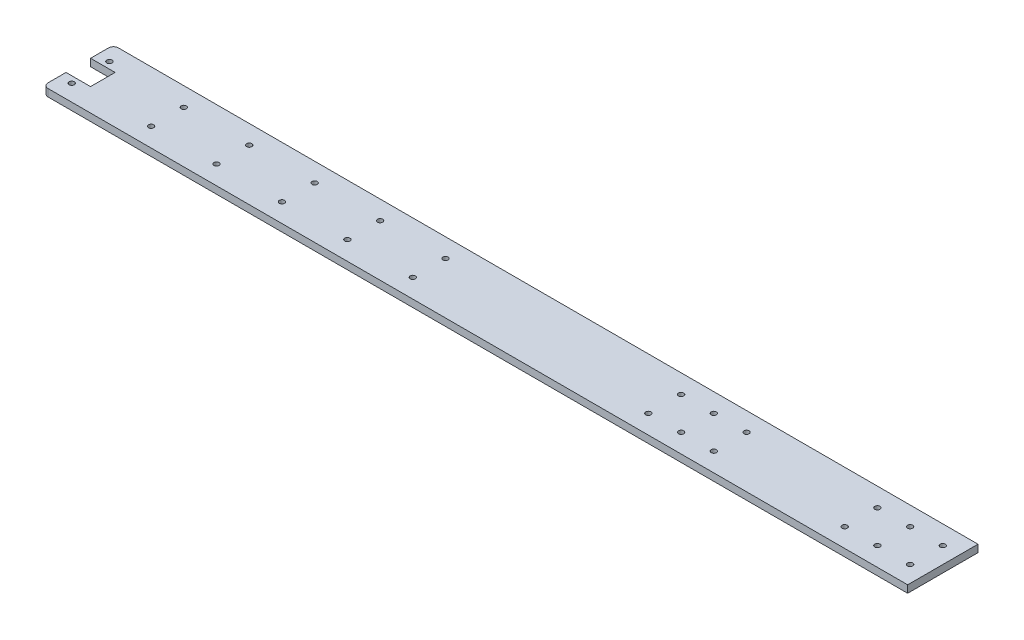
from build123d import *

# Parameters (mm, degrees)
SKETCH1_W           = 528.5
SKETCH1_H           = 43
SKETCH1_R           = 1.6
BOSS_EXTRUDE1_DEPTH = 4.5
SKETCH2_R           = 1.6
SKETCH2_W           = 15
SKETCH2_H           = 15
CUT_EXTRUDE1_DEPTH  = 5.5
FILLET1_R           = 3


with BuildPart() as part:
    # Sketch1 → Boss-Extrude1 (new body)
    with BuildSketch(Plane(origin=(0, 0, 0), x_dir=(1, 0, 0), z_dir=(0, 1, 0))):
        Rectangle(SKETCH1_W, SKETCH1_H)
        with Locations((-209.75, 10)):
            Circle(SKETCH1_R, mode=Mode.SUBTRACT)
        with Locations((-169.75, 10)):
            Circle(SKETCH1_R, mode=Mode.SUBTRACT)
        with Locations((-129.75, 10)):
            Circle(SKETCH1_R, mode=Mode.SUBTRACT)
        with Locations((-89.75, 10)):
            Circle(SKETCH1_R, mode=Mode.SUBTRACT)
        with Locations((-49.75, 10)):
            Circle(SKETCH1_R, mode=Mode.SUBTRACT)
        with Locations((-169.75, -10)):
            Circle(SKETCH1_R, mode=Mode.SUBTRACT)
        with Locations((-129.75, -10)):
            Circle(SKETCH1_R, mode=Mode.SUBTRACT)
        with Locations((-89.75, -10)):
            Circle(SKETCH1_R, mode=Mode.SUBTRACT)
        with Locations((-49.75, -10)):
            Circle(SKETCH1_R, mode=Mode.SUBTRACT)
        with Locations((-209.75, -10)):
            Circle(SKETCH1_R, mode=Mode.SUBTRACT)
        with Locations((234.25, 10)):
            Circle(SKETCH1_R, mode=Mode.SUBTRACT)
        with Locations((114.25, 10)):
            Circle(SKETCH1_R, mode=Mode.SUBTRACT)
        with Locations((114.25, -10)):
            Circle(SKETCH1_R, mode=Mode.SUBTRACT)
        with Locations((234.25, -10)):
            Circle(SKETCH1_R, mode=Mode.SUBTRACT)
        with Locations((134.25, -10)):
            Circle(SKETCH1_R, mode=Mode.SUBTRACT)
        with Locations((134.25, 10)):
            Circle(SKETCH1_R, mode=Mode.SUBTRACT)
        with Locations((254.25, 10)):
            Circle(SKETCH1_R, mode=Mode.SUBTRACT)
        with Locations((254.25, -10)):
            Circle(SKETCH1_R, mode=Mode.SUBTRACT)
        with Locations((94.25, -10)):
            Circle(SKETCH1_R, mode=Mode.SUBTRACT)
        with Locations((94.25, 10)):
            Circle(SKETCH1_R, mode=Mode.SUBTRACT)
        with Locations((214.25, 10)):
            Circle(SKETCH1_R, mode=Mode.SUBTRACT)
        with Locations((214.25, -10)):
            Circle(SKETCH1_R, mode=Mode.SUBTRACT)
    extrude(amount=BOSS_EXTRUDE1_DEPTH)

    # Sketch2 → Cut-Extrude1 (cut, through all)
    with BuildSketch(Plane(origin=(0, 4.5, 0), x_dir=(1, 0, 0), z_dir=(0, 1, 0))):
        with Locations((-256.75, 11.5)):
            Circle(SKETCH2_R)
        with Locations((-256.75, -11.5)):
            Circle(SKETCH2_R)
        with Locations((-256.75, 0)):
            Rectangle(SKETCH2_W, SKETCH2_H)
    extrude(amount=-CUT_EXTRUDE1_DEPTH, mode=Mode.SUBTRACT)

    # Fillet1
    fillet1_edges = [part.edges().sort_by_distance(p)[0] for p in [
        (-264.25, 2.25, 21.5),
        (-264.25, 2.25, -21.5),
    ]]
    fillet(fillet1_edges, radius=FILLET1_R)


solid = part.part
